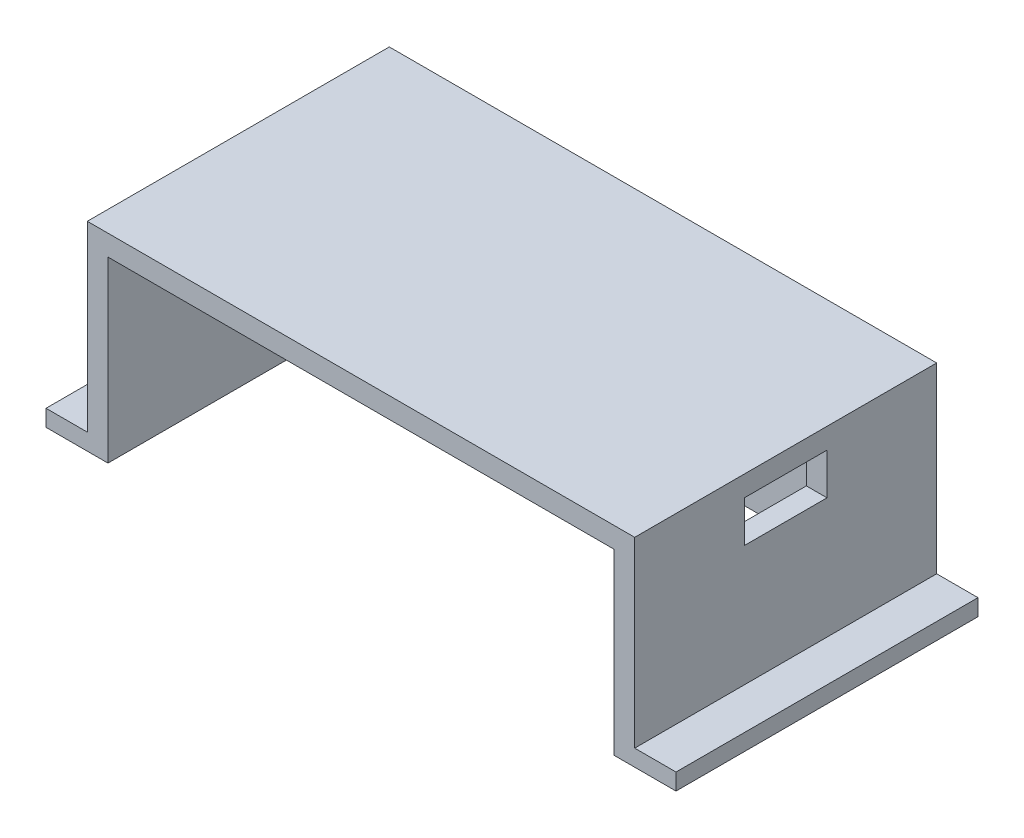
from build123d import *

# Parameters (mm, degrees)
SKETCH_1_W          = 132.5
SKETCH_1_H          = 73.1
EXTRUDE_1_DEPTH     = 48.2
SKETCH_3_W          = 122.5
SKETCH_3_H          = 43.2
CUT_EXTRUDE_1_DEPTH = 68.1
SKETCH_7_W          = 20
SKETCH_7_H          = 10
CUT_EXTRUDE_2_DEPTH = 10
SKETCH_8_W          = 73.1
SKETCH_8_H          = 4
EXTRUDE_2_DEPTH     = 10
SKETCH_9_W          = 73.1
SKETCH_9_H          = 4
EXTRUDE_3_DEPTH     = 10


with BuildPart() as part:
    # 草圖1 → 填料-伸長1 (new body)
    with BuildSketch(Plane(origin=(0, 0, 0), x_dir=(1, 0, 0), z_dir=(0, 1, 0))):
        Rectangle(SKETCH_1_W, SKETCH_1_H)
    extrude(amount=EXTRUDE_1_DEPTH)

    # 草圖3 → 除料-伸長1 (cut)
    with BuildSketch(Plane.XY.offset(36.55)):
        with Locations((0, 21.6)):
            Rectangle(SKETCH_3_W, SKETCH_3_H)
    extrude(amount=-CUT_EXTRUDE_1_DEPTH, mode=Mode.SUBTRACT)

    # 草圖7 → 除料-伸長2 (cut)
    with BuildSketch(Plane(origin=(66.25, 0, 0), x_dir=(0, 0, -1), z_dir=(1, 0, 0))):
        with Locations((0, 38.2)):
            Rectangle(SKETCH_7_W, SKETCH_7_H)
    extrude(amount=-CUT_EXTRUDE_2_DEPTH, mode=Mode.SUBTRACT)

    # 草圖8 → 填料-伸長2 (add)
    with BuildSketch(Plane(origin=(66.25, 0, 0), x_dir=(0, 0, -1), z_dir=(1, 0, 0))):
        with Locations((0, 2)):
            Rectangle(SKETCH_8_W, SKETCH_8_H)
    extrude(amount=EXTRUDE_2_DEPTH)

    # 草圖9 → 填料-伸長3 (add)
    with BuildSketch(Plane.ZY.offset(66.25)):
        with Locations((0, 2)):
            Rectangle(SKETCH_9_W, SKETCH_9_H)
    extrude(amount=EXTRUDE_3_DEPTH)


solid = part.part
